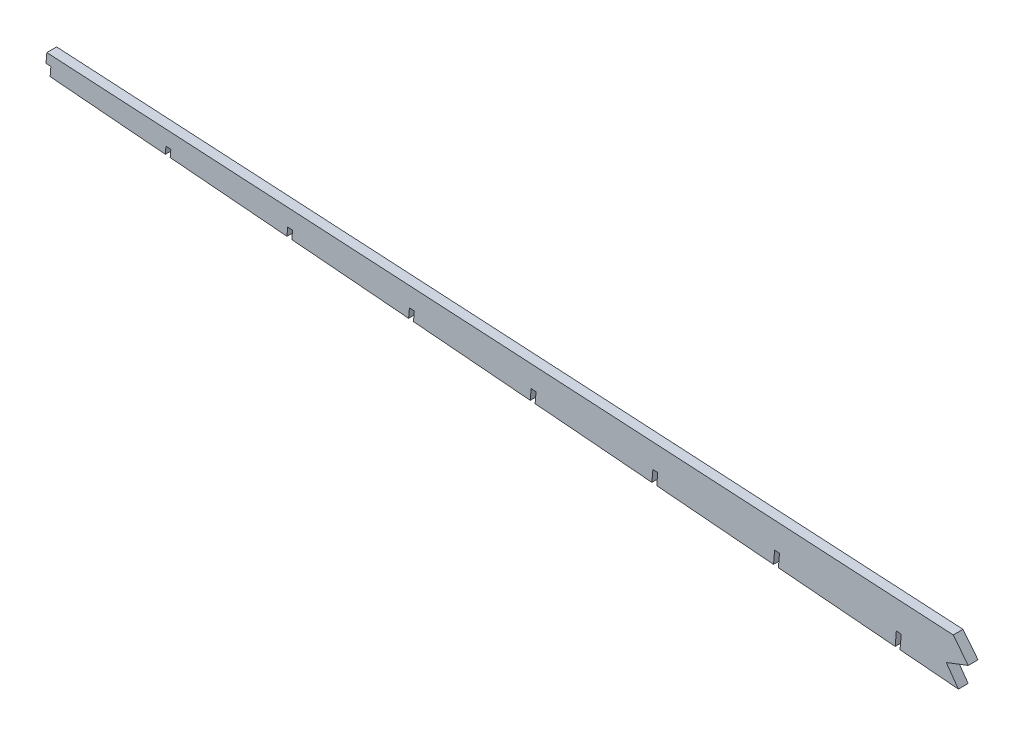
from build123d import *

# Parameters (mm, degrees)
BOSS_EXTRUDE1_DEPTH = 3.175
CUT_EXTRUDE1_DEPTH  = 7.35
CUT_EXTRUDE2_DEPTH  = 7.62


with BuildPart() as part:
    # Sketch1 → Boss-Extrude1 (new body, symmetric)
    with BuildSketch(Plane.XY):
        Polygon((76.2, 37.697541537), (76.2, 56.747541537), (79.375, 56.747541537), (79.375, 37.697541537), (92.075, 37.697541537), (92.075, 46.587541537), (95.25, 46.587541537), (95.25, 37.697541537), (136.525, 37.697541537), (136.525, 46.587541537), (139.7, 46.587541537), (139.7, 37.697541537), (152.4, 37.697541537), (152.4, 69.447541537), (0, 69.447541537), (-0.423998633, 69.491926731), (-3.587863461, 69.757603883), (-946.051908629, 122.953392794), (-946.583462345, 116.623288424), (-943.412318182, 116.444298555), (-943.91275138, 110.48479854), (-6.775989292, 31.791225946), (-5.713280681, 44.446685258), (-2.549415853, 44.181008106), (-3.612124464, 31.525548794), (-1.492292584, 31.347541537), (0, 31.347541537), (0, 44.047541537), (3.175, 44.047541537), (3.175, 31.347541537), (15.875, 31.347541537), (15.875, 36.427541537), (19.05, 36.427541537), (19.05, 31.347541537), (25.4, 31.347541537), (69.85, 37.697541537), align=None)
    extrude(amount=BOSS_EXTRUDE1_DEPTH, both=True)

    # Sketch2 → Cut-Extrude1 (cut, through all)
    with BuildSketch(Plane.XY.offset(3.175)):
        Polygon((-76.254460917, 37.625496217), (-75.245037036, 49.646404609), (-78.411328309, 49.883186), (-79.418325745, 37.891173369), align=None)
        Polygon((-155.224527027, 44.256797945), (-154.27566721, 55.556468134), (-157.441958483, 55.793249525), (-158.388391855, 44.522475098), align=None)
        Polygon((-234.194593137, 50.888099674), (-233.306297384, 61.466531659), (-236.472588657, 61.70331305), (-237.358457965, 51.153776826), align=None)
        Polygon((-313.164659247, 57.519401402), (-312.336927558, 67.376595183), (-315.503218831, 67.613376574), (-316.328524075, 57.785078555), align=None)
        Polygon((-392.134725356, 64.15070313), (-391.367557732, 73.286658708), (-394.533849005, 73.523440099), (-395.298590185, 64.416380283), align=None)
        Polygon((-471.104791466, 70.782004859), (-470.398187906, 79.196722233), (-473.564479179, 79.433503624), (-474.268656294, 71.047682011), align=None)
        Polygon((-550.074857576, 77.413306587), (-549.42881808, 85.106785757), (-552.595109353, 85.343567149), (-553.238722404, 77.67898374), align=None)
        Polygon((-629.044923686, 84.044608316), (-628.459448254, 91.016849282), (-631.625739527, 91.253630673), (-632.208788514, 84.310285468), align=None)
        Polygon((-708.014989796, 90.675910044), (-707.490078428, 96.926912807), (-710.656369701, 97.163694198), (-711.178854624, 90.941587197), align=None)
        Polygon((-786.985055905, 97.307211772), (-786.520708602, 102.836976331), (-789.686999875, 103.073757723), (-790.148920734, 97.572888925), align=None)
        Polygon((-865.955122015, 103.938513501), (-865.551338776, 108.747039856), (-868.717630049, 108.983821247), (-869.118986843, 104.204190653), align=None)
    extrude(amount=-CUT_EXTRUDE1_DEPTH, mode=Mode.SUBTRACT)

    # Sketch3 → Cut-Extrude2 (cut)
    with BuildSketch(Plane.XY.offset(3.175)):
        Polygon((-354.231624716, 60.967890842), (-362.126685184, 71.979397876), (-347.872352174, 77.449083798), (-357.599036746, 89.739165772), (194.218411841, 89.739165772), (127.81181163, -85.755982461), align=None)
    extrude(amount=-CUT_EXTRUDE2_DEPTH, mode=Mode.SUBTRACT)


solid = part.part
